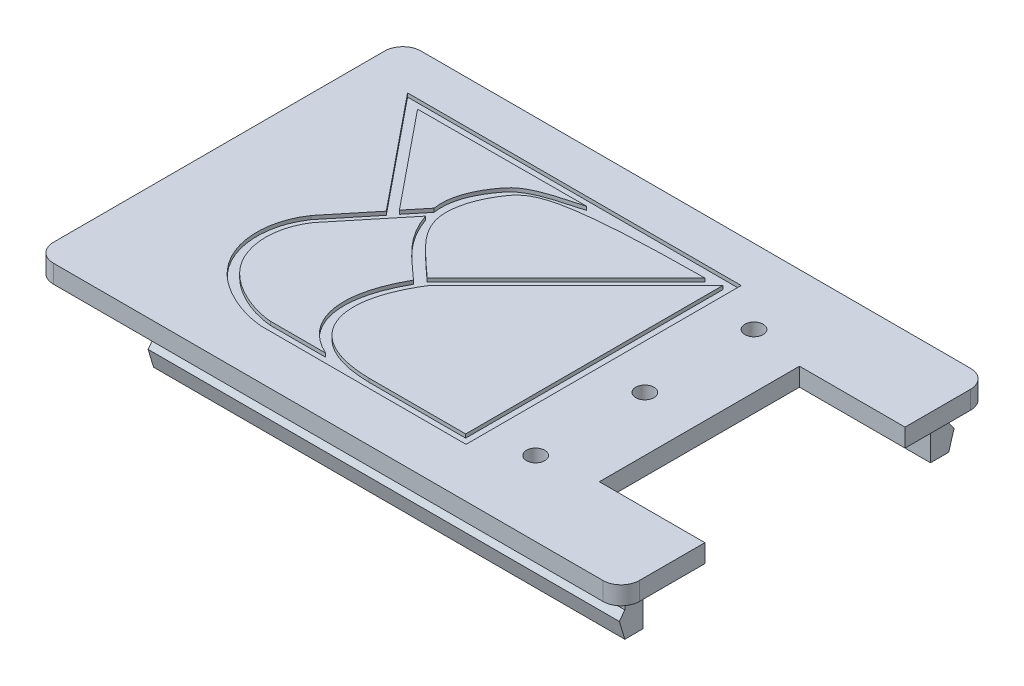
from build123d import *

# Parameters (mm, degrees)
BOSS_EXTRUDE1_DEPTH             = 1
BOSS_EXTRUDE2_DEPTH             = 2.4
BOSS_EXTRUDE3_REACH             = 18.1
BOSS_EXTRUDE3_DIRECTION_2_REACH = 18.1
BOSS_EXTRUDE4_DEPTH             = 5.3
FILLET1_R                       = 1
SKETCH5_W                       = 1
SKETCH5_H                       = 2.4
BOSS_EXTRUDE5_DEPTH             = 0.8
CUT_EXTRUDE1_DEPTH              = 0.2
BOSS_EXTRUDE6_DEPTH             = 11.5
SKETCH12_R                      = 0.5
CUT_EXTRUDE6_DEPTH              = 4.4


with BuildPart() as part:
    # Sketch1 → Boss-Extrude1 (new body)
    with BuildSketch(Plane(origin=(0, 0, 0), x_dir=(1, 0, 0), z_dir=(0, 1, 0))):
        Polygon((16.1, 5.5), (10.3, 5.5), (10.3, -5.5), (16.1, -5.5), (16.1, -10.1), (-16.1, -10.1), (-16.1, 10.1), (16.1, 10.1), align=None)
    extrude(amount=BOSS_EXTRUDE1_DEPTH)

    # Sketch2 → Boss-Extrude2 (add)
    with BuildSketch(Plane.XZ):
        Polygon((15.1, 8.9), (-10.8, 8.9), (-10.8, 7.9), (14.1, 7.9), (15.1, 7.9), align=None)
        Polygon((15.1, -8.9), (-15.3, -8.9), (-15.3, -7.9), (-14.3, -7.9), (14.1, -7.9), (15.1, -7.9), align=None)
    extrude(amount=BOSS_EXTRUDE2_DEPTH)

    # Boss-Extrude3: up to this face of the body (flat: up to its plane)
    boss_extrude3_end = Plane(part.part.faces().sort_by_distance((-10.8, -1.2, 8.4))[0])
    # Sketch3 → Boss-Extrude3 (add, up to the picked face)
    with BuildSketch(Plane(origin=(0, 0, 0), x_dir=(0, 0, -1), z_dir=(1, 0, 0)), mode=Mode.PRIVATE) as boss_extrude3_sk1:
        Polygon((8.9, -2.4), (9.2, -1.4), (8.9, -1), align=None)
    boss_extrude3_tool1 = split(extrude(boss_extrude3_sk1.sketch, amount=-BOSS_EXTRUDE3_REACH, mode=Mode.PRIVATE), bisect_by=boss_extrude3_end, keep=Keep.BOTH, mode=Mode.PRIVATE)
    add(boss_extrude3_tool1.solids().sort_by_distance((0, -1.6, -9))[0])
    # Sketch3 → Boss-Extrude3 (add, up to the picked face)
    with BuildSketch(Plane(origin=(0, 0, 0), x_dir=(0, 0, -1), z_dir=(1, 0, 0)), mode=Mode.PRIVATE) as boss_extrude3_sk2:
        Polygon((-8.9, -1), (-8.9, -2.4), (-9.2, -1.4), align=None)
    boss_extrude3_tool2 = split(extrude(boss_extrude3_sk2.sketch, amount=-BOSS_EXTRUDE3_REACH, mode=Mode.PRIVATE), bisect_by=boss_extrude3_end, keep=Keep.BOTH, mode=Mode.PRIVATE)
    add(boss_extrude3_tool2.solids().sort_by_distance((0, -1.6, 9))[0])

    # Boss-Extrude3 direction 2: up to this face of the body (flat: up to its plane)
    boss_extrude3_direction_2_end = Plane(part.part.faces().sort_by_distance((15.1, -1.2, -8.4))[0])
    # Sketch3 → Boss-Extrude3 direction 2 (add, up to the picked face)
    with BuildSketch(Plane(origin=(0, 0, 0), x_dir=(0, 0, -1), z_dir=(1, 0, 0)), mode=Mode.PRIVATE) as boss_extrude3_direction_2_sk1:
        Polygon((8.9, -2.4), (9.2, -1.4), (8.9, -1), align=None)
    boss_extrude3_direction_2_tool1 = split(extrude(boss_extrude3_direction_2_sk1.sketch, amount=BOSS_EXTRUDE3_DIRECTION_2_REACH, mode=Mode.PRIVATE), bisect_by=boss_extrude3_direction_2_end, keep=Keep.BOTH, mode=Mode.PRIVATE)
    add(boss_extrude3_direction_2_tool1.solids().sort_by_distance((0, -1.6, -9))[0])
    # Sketch3 → Boss-Extrude3 direction 2 (add, up to the picked face)
    with BuildSketch(Plane(origin=(0, 0, 0), x_dir=(0, 0, -1), z_dir=(1, 0, 0)), mode=Mode.PRIVATE) as boss_extrude3_direction_2_sk2:
        Polygon((-8.9, -1), (-8.9, -2.4), (-9.2, -1.4), align=None)
    boss_extrude3_direction_2_tool2 = split(extrude(boss_extrude3_direction_2_sk2.sketch, amount=BOSS_EXTRUDE3_DIRECTION_2_REACH, mode=Mode.PRIVATE), bisect_by=boss_extrude3_direction_2_end, keep=Keep.BOTH, mode=Mode.PRIVATE)
    add(boss_extrude3_direction_2_tool2.solids().sort_by_distance((0, -1.6, 9))[0])

    # Sketch4 → Boss-Extrude4 (add)
    with BuildSketch(Plane.ZY.offset(10.8)):
        Polygon((-8.9, -2.4), (-8.9, -1), (-9.2, -1.4), align=None)
    extrude(amount=BOSS_EXTRUDE4_DEPTH)

    # Fillet1
    fillet1_edges = [part.edges().sort_by_distance(p)[0] for p in [
        (-16.1, 0.5, 10.1),
        (16.1, 0.5, 10.1),
        (16.1, 0.5, -10.1),
        (-16.1, 0.5, -10.1),
    ]]
    fillet(fillet1_edges, radius=FILLET1_R)

    # Sketch5 → Boss-Extrude5 (add)
    with BuildSketch(Plane.ZY.offset(15.3)):
        with Locations((-8.4, -1.2)):
            Rectangle(SKETCH5_W, SKETCH5_H)
    extrude(amount=BOSS_EXTRUDE5_DEPTH)

    # Sketch9 → Cut-Extrude1 (cut)
    with BuildSketch(Plane(origin=(0, 1, 0), x_dir=(1, 0, 0), z_dir=(0, 1, 0))):
        with BuildLine():
            add(Edge.make_bspline(
                [(-3.342815403, -6.898771532), (-3.392032296, -6.876638055), (-3.827458148, -6.670816542), (-4.519691405, -6.171060382), (-5.129218139, -5.217739053), (-5.348913685, -4.118130523), (-5.230008041, -2.951908877), (-4.894461229, -1.967151288), (-4.588355912, -1.345070717), (-4.453256479, -1.098754494), (-4.417927521, -1.036087622), (-4.4033747, -1.01056214)],
                knots=[0.234294725, 0.234294725, 0.234294725, 0.234294725, 0.249919787, 0.375, 0.5, 0.625, 0.75, 0.875, 0.931300557, 0.942750464, 0.95062349, 0.95062349, 0.95062349, 0.95062349], degree=3))
            add(Edge.make_bspline(
                [(-3.342815403, -6.898771532), (-2.542251184, -7.287796887), (-1.658619274, -7.383876714)],
                knots=[0, 0, 0, 1, 1, 1], degree=2))
            Line((-1.658619274, -7.383876714), (-0.948898515, -7.383876714))
            Line((-0.948898515, -7.383876714), (4.858590941, -7.383876714))
            Line((4.858590941, -7.383876714), (4.858590941, 7.737734352))
            Line((4.858590941, 7.737734352), (-3.156218351, 7.262620046))
            add(Edge.make_bspline(
                [(-3.156218351, 7.262620046), (-4.204686525, 6.965216897), (-5.726735189, 6.631756812), (-7.011707154, 4.951403609), (-7.402848959, 3.939339374), (-7.264734741, 2.979074857)],
                knots=[0.007330404, 0.007330404, 0.007330404, 0.007330404, 0.225500981, 0.280065017, 0.552970764, 0.552970764, 0.552970764, 0.552970764], degree=3))
            Line((-7.264734741, 2.979074857), (-7.117659595, 2.367238768))
            add(Edge.make_bspline(
                [(-7.117659595, 2.367238768), (-6.960941749, 1.890945903), (-6.272373332, 0.577066844), (-5.102929425, -0.364874806), (-4.4033747, -1.01056214)],
                knots=[0.609519995, 0.609519995, 0.609519995, 0.609519995, 0.739586039, 0.961717779, 0.961717779, 0.961717779, 0.961717779], degree=3))
        make_face()
        with BuildLine():
            Line((-3.689882661, -0.799866909), (4.352426166, 7.237734352))
            Line((4.352426166, 7.237734352), (4.352426166, -6.898771532))
            Line((4.352426166, -6.898771532), (0.040224346, -6.898771532))
            Line((0.040224346, -6.898771532), (-0.948898515, -6.898771532))
            add(Edge.make_bspline(
                [(-0.948898515, -6.898771532), (-5.034514831, -6.847494081), (-5.677385917, -3.860270153), (-3.689882661, -0.799866909)],
                knots=[0, 0, 0, 0, 1, 1, 1, 1], degree=3))
        make_face(mode=Mode.SUBTRACT)
        with BuildLine():
            Line((3.506059361, 7.097194921), (-4.128123279, -0.530951144))
            add(Edge.make_bspline(
                [(3.506059361, 7.097194921), (-3.269089821, 7.048794638), (-5.221862409, 6.449276012), (-6.471825808, 4.765768499), (-7.041574265, 2.901212273), (-5.99383179, 1.096583313), (-4.827678003, 0.11473619), (-4.128123279, -0.530951144)],
                knots=[0.007330404, 0.007330404, 0.007330404, 0.007330404, 0.225500981, 0.28162106, 0.568531193, 0.739586039, 0.961717779, 0.961717779, 0.961717779, 0.961717779], degree=3))
        make_face(mode=Mode.SUBTRACT)
        with BuildLine():
            add(Edge.make_bspline(
                [(-3.342815403, -6.898771532), (-2.542251184, -7.287796887), (-1.658619274, -7.383876714)],
                knots=[0, 0, 0, 1, 1, 1], degree=2))
            Line((-3.342815403, -6.898771532), (-6.38229421, -6.898771532))
            add(Edge.make_bspline(
                [(-9.901940455, -1.035163603), (-10.745351374, -2.262822828), (-10.813877235, -5.298026757), (-7.511264228, -6.800208927), (-6.38229421, -6.898771532)],
                knots=[0, 0, 0, 0, 0.624222909, 1, 1, 1, 1], degree=3))
            Line((-9.901940455, -1.035163603), (-7.799125954, 1.534484145))
            Line((-7.799125954, 1.534484145), (-7.117659595, 2.367238768))
            Line((-7.117659595, 2.367238768), (-7.264734741, 2.979074857))
            Line((-7.264734741, 2.979074857), (-8.121685172, 1.931877995))
            Line((-8.121685172, 1.931877995), (-12.428377088, 7.237734352))
            Line((-12.428377088, 7.237734352), (-3.156218351, 7.262620046))
            Line((-3.156218351, 7.262620046), (4.858590941, 7.737734352))
            Line((4.858590941, 7.737734352), (-13.478199155, 7.737734352))
            Line((-13.478199155, 7.737734352), (-8.434565478, 1.523963693))
            Line((-8.434565478, 1.523963693), (-10.290254207, -0.743695372))
            add(Edge.make_bspline(
                [(-10.290254207, -0.743695372), (-10.681696867, -1.313474801), (-11.163382472, -2.664450315), (-10.847207421, -4.528853246), (-9.910083857, -5.835484729), (-8.881232555, -6.617480767), (-7.669601654, -7.167356574), (-6.83032417, -7.346607487), (-6.403429612, -7.383876714)],
                knots=[-0.002843331, -0.002843331, -0.002843331, -0.002843331, 0.248451523, 0.499746376, 0.625393803, 0.75104123, 0.876688657, 1.002336083, 1.002336083, 1.002336083, 1.002336083], degree=3))
            Line((-6.403429612, -7.383876714), (-1.658619274, -7.383876714))
        make_face()
    extrude(amount=-CUT_EXTRUDE1_DEPTH, mode=Mode.SUBTRACT)

    # Sketch11 → Boss-Extrude6 (add)
    with BuildSketch(Plane.XY.offset(-7.9)):
        Polygon((-15.1, 0), (-14.6, 0), (-14.85, -0.3), align=None)
    extrude(amount=BOSS_EXTRUDE6_DEPTH)

    # Sketch12 → Cut-Extrude6 (cut, through all)
    with BuildSketch(Plane(origin=(0, 1, 0), x_dir=(1, 0, 0), z_dir=(0, 1, 0))):
        with Locations((7.3, 0)):
            Circle(SKETCH12_R)
        with Locations((7.3, -6)):
            Circle(SKETCH12_R)
        with Locations((7.3, 6)):
            Circle(SKETCH12_R)
    extrude(amount=-CUT_EXTRUDE6_DEPTH, mode=Mode.SUBTRACT)


solid = part.part
